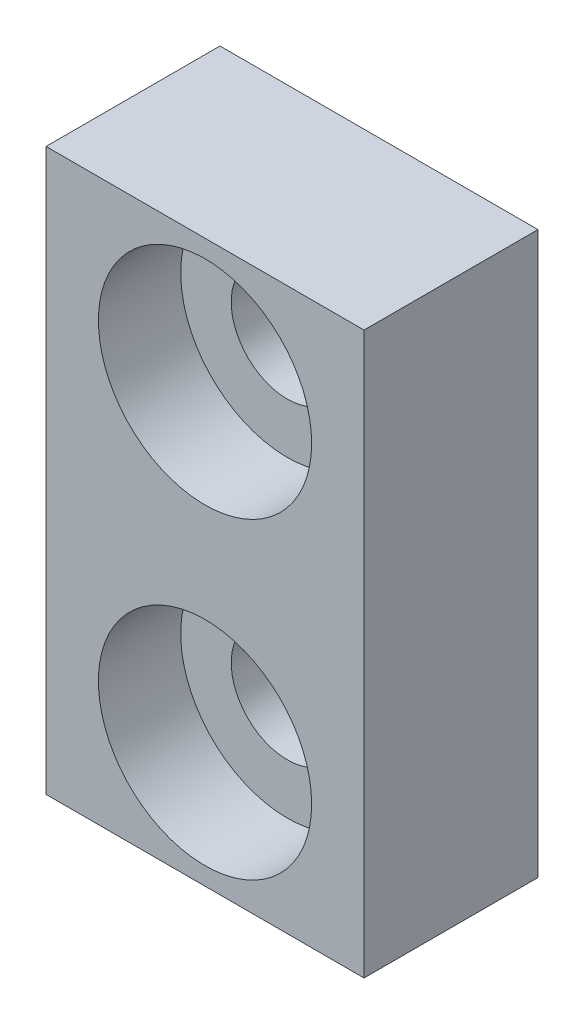
from build123d import *

# Parameters (mm, degrees)
SKETCH1_W                 = 8.5
SKETCH1_H                 = 15
BOSS_EXTRUDE1_DEPTH       = 4.65
F_3_0MM_DOWEL_HOLE1_D     = 3
F_3_0MM_DOWEL_HOLE1_DEPTH = 5
F_3_0MM_DOWEL_HOLE1_TIP   = 0.901290929
SKETCH2_R                 = 2.85
CUT_EXTRUDE2_DEPTH        = 2.2


with BuildPart() as part:
    # Sketch1 → Boss-Extrude1 (new body)
    with BuildSketch(Plane.XY):
        Rectangle(SKETCH1_W, SKETCH1_H)
    extrude(amount=BOSS_EXTRUDE1_DEPTH)

    # Ø3.0mm Dowel Hole1
    with Locations(Plane.XY.offset(4.65)):
        with Locations((0, 4.175), (0, -4.175)):
            Hole(F_3_0MM_DOWEL_HOLE1_D / 2, depth=F_3_0MM_DOWEL_HOLE1_DEPTH)
            with Locations((0, 0, -(F_3_0MM_DOWEL_HOLE1_DEPTH + F_3_0MM_DOWEL_HOLE1_TIP / 2))):  # 118° drill point
                Cone(0, F_3_0MM_DOWEL_HOLE1_D / 2, F_3_0MM_DOWEL_HOLE1_TIP, mode=Mode.SUBTRACT)

    # Sketch2 → Cut-Extrude2 (cut)
    with BuildSketch(Plane.XY.offset(4.65)):
        with Locations((0, -4.175)):
            Circle(SKETCH2_R)
        with Locations((0, 4.175)):
            Circle(SKETCH2_R)
    extrude(amount=-CUT_EXTRUDE2_DEPTH, mode=Mode.SUBTRACT)


solid = part.part
